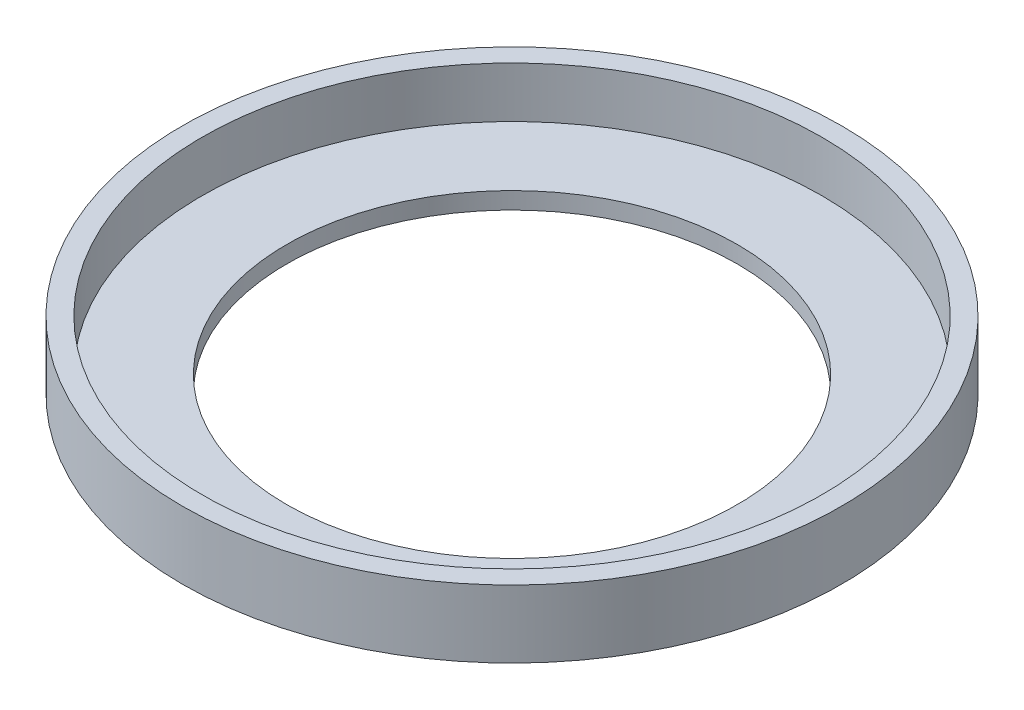
from build123d import *


with BuildPart() as part:
    # Эскиз1 → Повернуть1 (revolve)
    with BuildSketch(Plane.XY):
        Polygon((4, 0), (5.85, 0), (5.85, 1.2), (5.5, 1.2), (5.5, 0.3), (4, 0.3), align=None)
    revolve(axis=Axis((0, 0, 0), (0, 1, 0)))


solid = part.part
